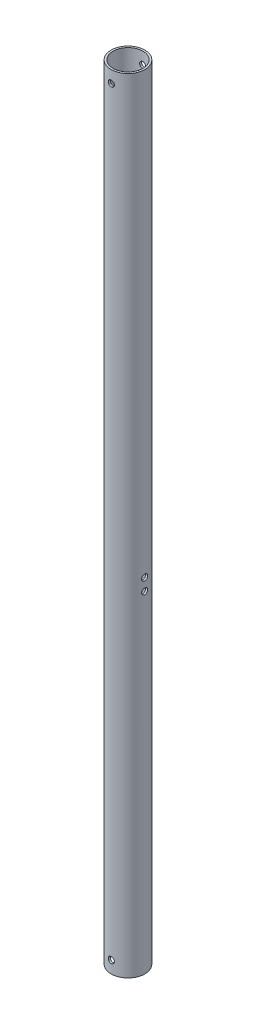
from build123d import *

# Parameters (mm, degrees)
SKETCH1_R               = 14
SKETCH1_R_2             = 12.4125
BOSS_EXTRUDE1_DEPTH     = 650
SKETCH2_R               = 2.5
CUT_EXTRUDE2_DEPTH      = 15
CUT_EXTRUDE2_DEPTH_BACK = 15
SKETCH6_R               = 2.5
CUT_EXTRUDE4_DEPTH      = 15.0000001
CUT_EXTRUDE4_DEPTH_BACK = 15.0000001


with BuildPart() as part:
    # Sketch1 → Boss-Extrude1 (new body)
    with BuildSketch(Plane(origin=(0, 0, 0), x_dir=(1, 0, 0), z_dir=(0, 1, 0))):
        Circle(SKETCH1_R)
        Circle(SKETCH1_R_2, mode=Mode.SUBTRACT)
    extrude(amount=BOSS_EXTRUDE1_DEPTH)

    # Sketch2 → Cut-Extrude2 (cut, two sides)
    with BuildSketch(Plane.XY) as cut_extrude2_sk:
        with Locations((0, 10)):
            Circle(SKETCH2_R)
        with Locations((0, 640)):
            Circle(SKETCH2_R)
    extrude(amount=CUT_EXTRUDE2_DEPTH, mode=Mode.SUBTRACT)
    extrude(cut_extrude2_sk.sketch, amount=-CUT_EXTRUDE2_DEPTH_BACK, mode=Mode.SUBTRACT)

    # Sketch6 → Cut-Extrude4 (cut, two sides)
    with BuildSketch(Plane(origin=(0, 0, 0), x_dir=(0, 0, -1), z_dir=(1, 0, 0))) as cut_extrude4_sk:
        with Locations((0, 285)):
            Circle(SKETCH6_R)
        with Locations((0, 275)):
            Circle(SKETCH6_R)
    extrude(amount=CUT_EXTRUDE4_DEPTH, mode=Mode.SUBTRACT)
    extrude(cut_extrude4_sk.sketch, amount=-CUT_EXTRUDE4_DEPTH_BACK, mode=Mode.SUBTRACT)


solid = part.part
